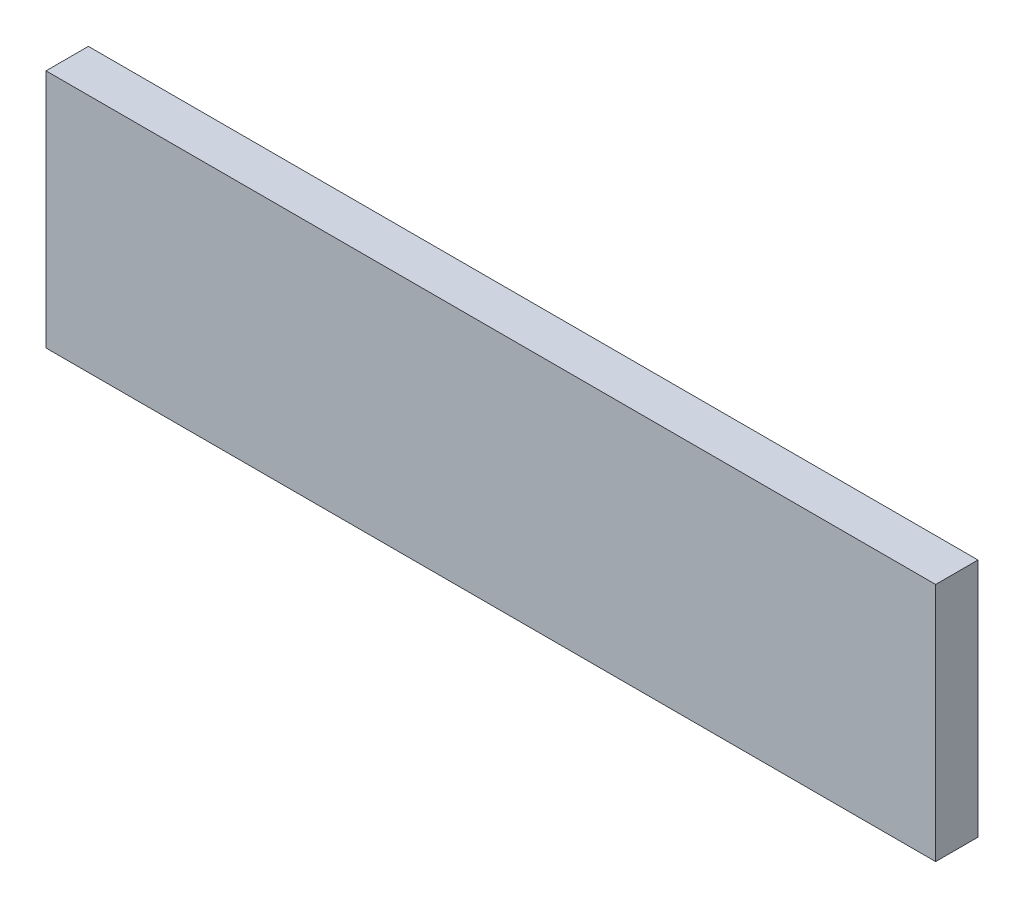
from build123d import *

# Parameters (mm, degrees)
SKETCH1_W           = 400.05
SKETCH1_H           = 107.95
BOSS_EXTRUDE1_DEPTH = 19.05


with BuildPart() as part:
    # Sketch1 → Boss-Extrude1 (new body)
    with BuildSketch(Plane.XY):
        Rectangle(SKETCH1_W, SKETCH1_H)
    extrude(amount=BOSS_EXTRUDE1_DEPTH)


solid = part.part
